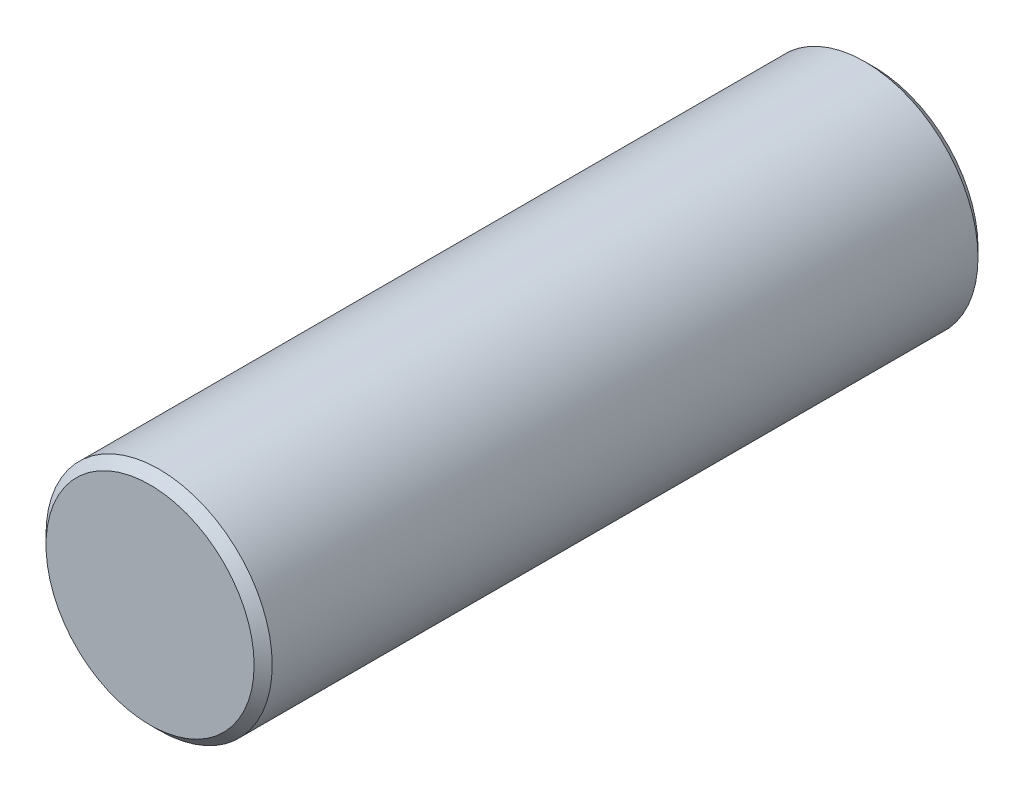
from build123d import *

# Parameters (mm, degrees)
SKETCH1_R           = 2.5
BOSS_EXTRUDE1_DEPTH = 16
CHAMFER1_SIZE       = 0.2


with BuildPart() as part:
    # Sketch1 → Boss-Extrude1 (new body)
    with BuildSketch(Plane.XY):
        Circle(SKETCH1_R)
    extrude(amount=BOSS_EXTRUDE1_DEPTH)

    # Chamfer1
    chamfer1_edges = [part.edges().sort_by_distance(p)[0] for p in [
        (-2.5, 0, 0),
        (-2.5, 0, 16),
    ]]
    chamfer(chamfer1_edges, length=CHAMFER1_SIZE)


solid = part.part
